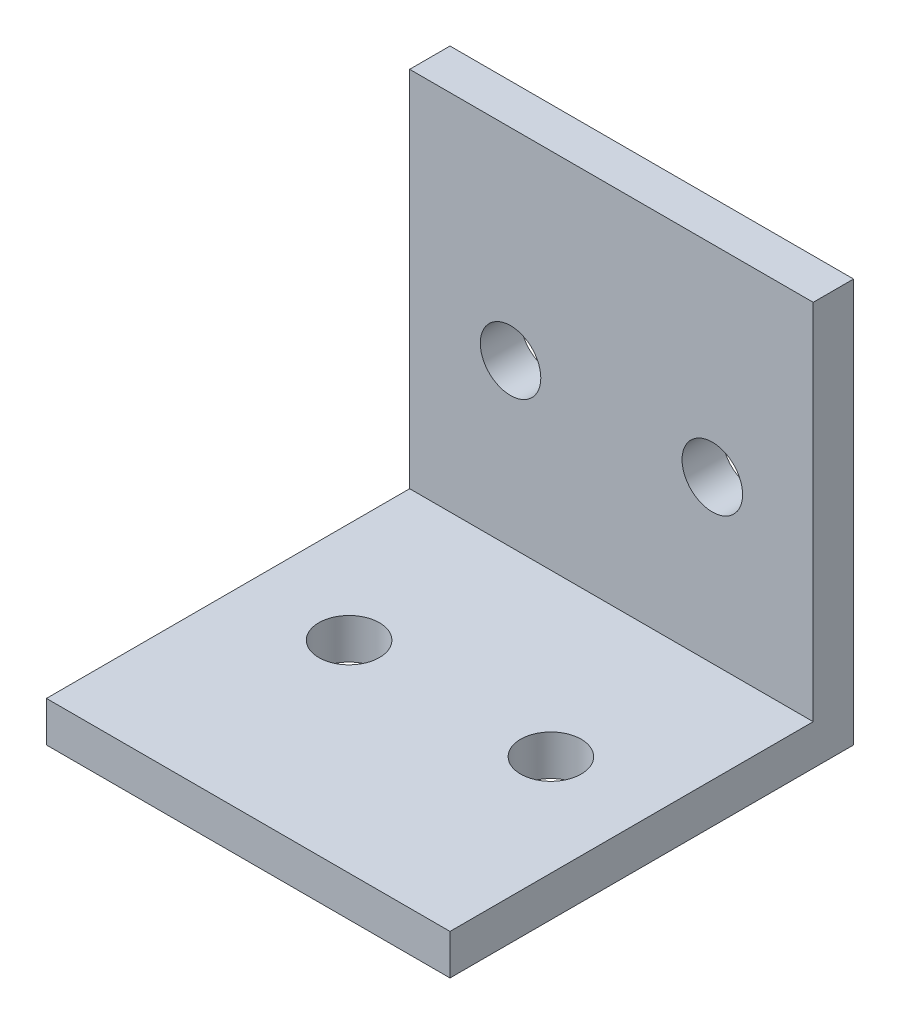
from build123d import *

# Parameters (mm, degrees)
SKETCH_1_W          = 20
SKETCH_1_H          = 20
EXTRUDE_1_DEPTH     = 2
SKETCH_2_W          = 20
SKETCH_2_H          = 2
EXTRUDE_2_DEPTH     = 18
SKETCH_4_R          = 1.5
CUT_EXTRUDE_1_DEPTH = 18
SKETCH_6_R          = 1.5
CUT_EXTRUDE_2_DEPTH = 18


with BuildPart() as part:
    # 草图1 → 凸台-拉伸1 (new body)
    with BuildSketch(Plane.XY):
        Rectangle(SKETCH_1_W, SKETCH_1_H)
    extrude(amount=EXTRUDE_1_DEPTH)

    # 草图2 → 凸台-拉伸2 (add)
    with BuildSketch(Plane.XY.offset(2)):
        with Locations((0, -9)):
            Rectangle(SKETCH_2_W, SKETCH_2_H)
    extrude(amount=EXTRUDE_2_DEPTH)

    # 草图4 → 切除-拉伸1 (cut)
    with BuildSketch(Plane.XZ.offset(10)):
        with Locations((-5, 10)):
            Circle(SKETCH_4_R)
        with Locations((5, 10)):
            Circle(SKETCH_4_R)
    extrude(amount=-CUT_EXTRUDE_1_DEPTH, mode=Mode.SUBTRACT)

    # 草图6 → 切除-拉伸2 (cut)
    with BuildSketch(Plane(origin=(0, 0, 0), x_dir=(-1, 0, 0), z_dir=(0, 0, -1))):
        with Locations((5, 0)):
            Circle(SKETCH_6_R)
        with Locations((-5, 0)):
            Circle(SKETCH_6_R)
    extrude(amount=-CUT_EXTRUDE_2_DEPTH, mode=Mode.SUBTRACT)


solid = part.part
